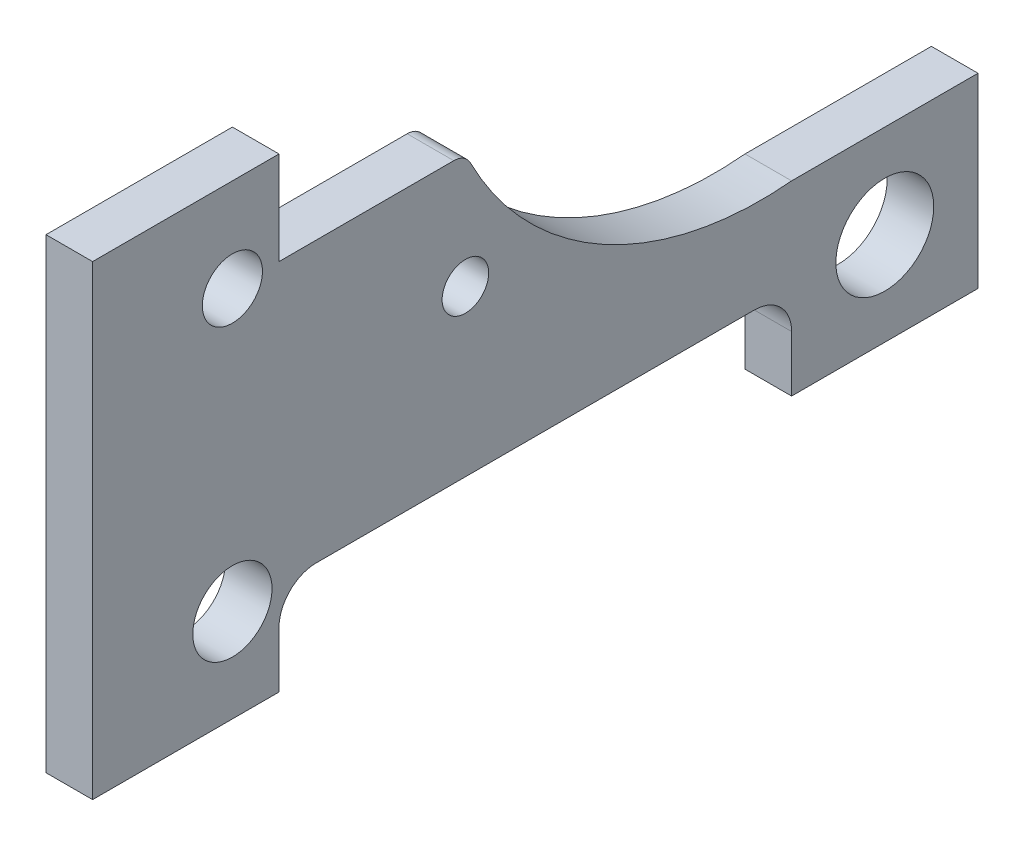
from build123d import *

# Parameters (mm, degrees)
SKETCH7_R           = 3.225
SKETCH7_R_2         = 4.25
SKETCH7_R_3         = 2.5
SKETCH7_R_4         = 5.25
BOSS_EXTRUDE5_DEPTH = 5
FILLET1_R           = 4
FILLET2_R           = 2


with BuildPart() as part:
    # Sketch7 → Boss-Extrude5 (new body)
    with BuildSketch(Plane(origin=(0, 0, 0), x_dir=(0, 0, -1), z_dir=(1, 0, 0))):
        with BuildLine():
            Line((0, 0), (20, 0))
            Line((20, 0), (20, 10))
            Line((20, 10), (75, 10))
            Line((75, 10), (75, 0))
            Line((75, 0), (95, 0))
            Line((95, 0), (95, 20))
            Line((95, 20), (75, 20))
            ThreePointArc((75, 20), (54.331561409, 24.455232466), (40, 40))
            Line((40, 40), (20, 40))
            Line((20, 40), (20, 50))
            Line((20, 50), (0, 50))
            Line((0, 50), (0, 0))
        make_face()
        with Locations((15, 40)):
            Circle(SKETCH7_R, mode=Mode.SUBTRACT)
        with Locations((15, 10)):
            Circle(SKETCH7_R_2, mode=Mode.SUBTRACT)
        with Locations((40, 27.700051953)):
            Circle(SKETCH7_R_3, mode=Mode.SUBTRACT)
        with Locations((85, 10)):
            Circle(SKETCH7_R_4, mode=Mode.SUBTRACT)
    extrude(amount=BOSS_EXTRUDE5_DEPTH)

    # Fillet1
    fillet1_edges = [part.edges().sort_by_distance(p)[0] for p in [
        (2.5, 10, -75),
        (2.5, 10, -20),
    ]]
    fillet(fillet1_edges, radius=FILLET1_R)

    # Fillet2
    fillet2_edges = [part.edges().sort_by_distance(p)[0] for p in [
        (2.5, 40, -40),
    ]]
    fillet(fillet2_edges, radius=FILLET2_R)


solid = part.part
